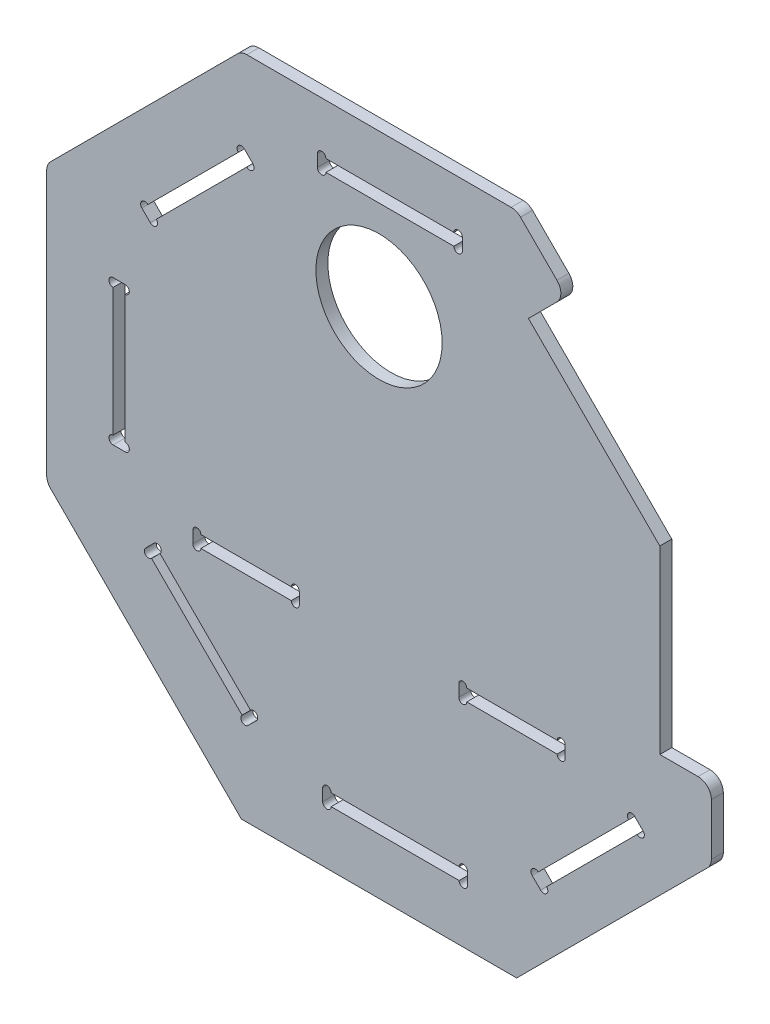
from build123d import *

# Parameters (mm, degrees)
SKETCH1_R           = 47.5
BOSS_EXTRUDE1_DEPTH = 4.5


with BuildPart() as part:
    # Sketch1 → Boss-Extrude1 (new body, symmetric)
    with BuildSketch(Plane.XY):
        with BuildLine():
            Line((250, -99.41125497), (250, -60.550262484))
            ThreePointArc((250, -60.550262484), (247.071067812, -53.479194672), (240, -50.550262484))
            Line((240, -50.550262484), (211.253965719, -50.550262484))
            Line((211.253965719, -50.550262484), (211.253965719, 85.284392818))
            Line((211.253965719, 85.284392818), (112.411473654, 184.126884883))
            Line((112.411473654, 184.126884883), (133.84792187, 205.563333099))
            ThreePointArc((133.84792187, 205.563333099), (136.776854058, 212.634400911), (133.84792187, 219.705468723))
            Line((133.84792187, 219.705468723), (106.482322781, 247.071067812))
            ThreePointArc((106.482322781, 247.071067812), (103.238089293, 249.238795325), (99.41125497, 250))
            Line((99.41125497, 250), (-99.41125497, 250))
            ThreePointArc((-99.41125497, 250), (-103.238089293, 249.238795325), (-106.482322781, 247.071067812))
            Line((-106.482322781, 247.071067812), (-247.071067812, 106.482322781))
            ThreePointArc((-247.071067812, 106.482322781), (-249.238795325, 103.238089293), (-250, 99.41125497))
            Line((-250, 99.41125497), (-250, -99.41125497))
            ThreePointArc((-250, -99.41125497), (-249.238795325, -103.238089293), (-247.071067812, -106.482322781))
            Line((-247.071067812, -106.482322781), (-103.553390593, -250))
            Line((-103.553390593, -250), (103.553390593, -250))
            Line((103.553390593, -250), (247.071067812, -106.482322781))
            ThreePointArc((247.071067812, -106.482322781), (249.238795325, -103.238089293), (250, -99.41125497))
        make_face()
        with Locations((0, 135.632011386)):
            Circle(SKETCH1_R, mode=Mode.SUBTRACT)
        with BuildLine():
            Line((-200, 54.5), (-191, 54.5))
            ThreePointArc((-191, 54.5), (-187.82, 51.32), (-191, 48.14))
            Line((-191, 48.14), (-191, -48.14))
            ThreePointArc((-191, -48.14), (-187.82, -51.32), (-191, -54.5))
            Line((-191, -54.5), (-200, -54.5))
            ThreePointArc((-200, -54.5), (-203.18, -51.32), (-200, -48.14))
            Line((-200, -48.14), (-200, 48.14))
            ThreePointArc((-200, 48.14), (-203.18, 51.32), (-200, 54.5))
        make_face(mode=Mode.SUBTRACT)
        with BuildLine():
            Line((-105.811554275, 183.200760604), (-173.891795168, 115.120519711))
            ThreePointArc((-173.891795168, 115.120519711), (-178.388994296, 115.120519711), (-178.388994296, 110.623320583))
            Line((-178.388994296, 110.623320583), (-172.025033265, 104.259359552))
            ThreePointArc((-172.025033265, 104.259359552), (-167.527834137, 104.259359552), (-167.527834137, 108.756558681))
            Line((-167.527834137, 108.756558681), (-99.447593244, 176.836799573))
            ThreePointArc((-99.447593244, 176.836799573), (-94.950394116, 176.836799573), (-94.950394116, 181.333998701))
            Line((-94.950394116, 181.333998701), (-101.314355147, 187.697959732))
            ThreePointArc((-101.314355147, 187.697959732), (-105.811554275, 187.697959732), (-105.811554275, 183.200760604))
        make_face(mode=Mode.SUBTRACT)
        with BuildLine():
            Line((56.292114102, 212.101851618), (-39.987885898, 212.101851618))
            ThreePointArc((-39.987885898, 212.101851618), (-43.167885898, 215.281851618), (-46.347885898, 212.101851618))
            Line((-46.347885898, 212.101851618), (-46.347885898, 203.101851618))
            ThreePointArc((-46.347885898, 203.101851618), (-43.167885898, 199.921851618), (-39.987885898, 203.101851618))
            Line((-39.987885898, 203.101851618), (56.292114102, 203.101851618))
            ThreePointArc((56.292114102, 203.101851618), (59.472114102, 199.921851618), (62.652114102, 203.101851618))
            Line((62.652114102, 203.101851618), (62.652114102, 212.101851618))
            ThreePointArc((62.652114102, 212.101851618), (59.472114102, 215.281851618), (56.292114102, 212.101851618))
        make_face(mode=Mode.SUBTRACT)
        with BuildLine():
            Line((126.065519994, -179.251023088), (194.145760887, -111.170782195))
            ThreePointArc((194.145760887, -111.170782195), (198.642960015, -111.170782195), (198.642960015, -106.673583067))
            Line((198.642960015, -106.673583067), (192.278998984, -100.309622036))
            ThreePointArc((192.278998984, -100.309622036), (187.781799856, -100.309622036), (187.781799856, -104.806821165))
            Line((187.781799856, -104.806821165), (119.701558963, -172.887062057))
            ThreePointArc((119.701558963, -172.887062057), (115.204359835, -172.887062057), (115.204359835, -177.384261185))
            Line((115.204359835, -177.384261185), (121.568320866, -183.748222216))
            ThreePointArc((121.568320866, -183.748222216), (126.065519994, -183.748222216), (126.065519994, -179.251023088))
        make_face(mode=Mode.SUBTRACT)
        with BuildLine():
            Line((-36.038148382, -208.152114102), (60.241851618, -208.152114102))
            ThreePointArc((60.241851618, -208.152114102), (63.421851618, -211.332114102), (66.601851618, -208.152114102))
            Line((66.601851618, -208.152114102), (66.601851618, -199.152114102))
            ThreePointArc((66.601851618, -199.152114102), (63.421851618, -195.972114102), (60.241851618, -199.152114102))
            Line((60.241851618, -199.152114102), (-36.038148382, -199.152114102))
            ThreePointArc((-36.038148382, -199.152114102), (-39.218148382, -195.972114102), (-42.398148382, -199.152114102))
            Line((-42.398148382, -199.152114102), (-42.398148382, -208.152114102))
            ThreePointArc((-42.398148382, -208.152114102), (-39.218148382, -211.332114102), (-36.038148382, -208.152114102))
        make_face(mode=Mode.SUBTRACT)
        with BuildLine():
            Line((-171.098908986, -113.963668377), (-103.018668094, -182.043909269))
            ThreePointArc((-103.018668094, -182.043909269), (-103.018668094, -186.541108398), (-98.521468965, -186.541108398))
            Line((-98.521468965, -186.541108398), (-92.157507935, -180.177147367))
            ThreePointArc((-92.157507935, -180.177147367), (-92.157507935, -175.679948239), (-96.654707063, -175.679948239))
            Line((-96.654707063, -175.679948239), (-164.734947956, -107.599707346))
            ThreePointArc((-164.734947956, -107.599707346), (-164.734947956, -103.102508218), (-169.232147084, -103.102508218))
            Line((-169.232147084, -103.102508218), (-175.596108115, -109.466469248))
            ThreePointArc((-175.596108115, -109.466469248), (-175.596108115, -113.963668377), (-171.098908986, -113.963668377))
        make_face(mode=Mode.SUBTRACT)
        with BuildLine():
            Line((-134, -88.91125497), (-66, -88.91125497))
            ThreePointArc((-66, -88.91125497), (-63, -91.91125497), (-60, -88.91125497))
            Line((-60, -88.91125497), (-60, -79.91125497))
            ThreePointArc((-60, -79.91125497), (-63, -76.91125497), (-66, -79.91125497))
            Line((-66, -79.91125497), (-134, -79.91125497))
            ThreePointArc((-134, -79.91125497), (-137, -76.91125497), (-140, -79.91125497))
            Line((-140, -79.91125497), (-140, -88.91125497))
            ThreePointArc((-140, -88.91125497), (-137, -91.91125497), (-134, -88.91125497))
        make_face(mode=Mode.SUBTRACT)
        with BuildLine():
            Line((140, -88.91125497), (140, -79.91125497))
            ThreePointArc((140, -79.91125497), (137, -76.91125497), (134, -79.91125497))
            Line((134, -79.91125497), (66, -79.91125497))
            ThreePointArc((66, -79.91125497), (63, -76.91125497), (60, -79.91125497))
            Line((60, -79.91125497), (60, -88.91125497))
            ThreePointArc((60, -88.91125497), (63, -91.91125497), (66, -88.91125497))
            Line((66, -88.91125497), (134, -88.91125497))
            ThreePointArc((134, -88.91125497), (137, -91.91125497), (140, -88.91125497))
        make_face(mode=Mode.SUBTRACT)
    extrude(amount=BOSS_EXTRUDE1_DEPTH, both=True)


solid = part.part
